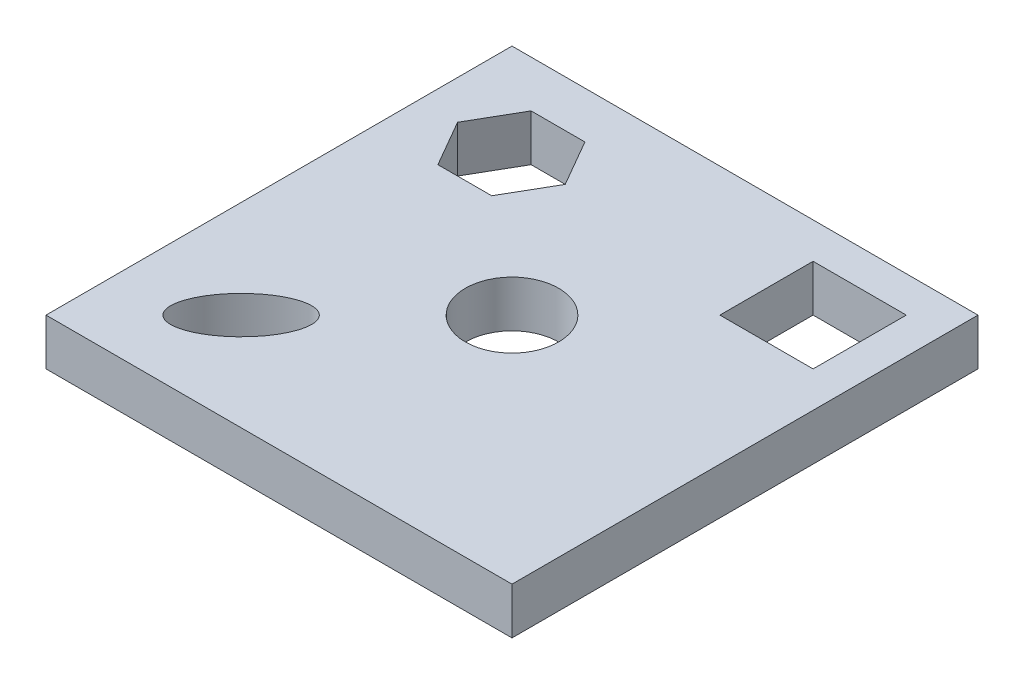
from build123d import *

# Parameters (mm, degrees)
SKETCH1_W           = 100
SKETCH1_H           = 100
SKETCH1_R           = 10
SKETCH1_RX          = 11.867112324
SKETCH1_RY          = 5.7171528
SKETCH1_W_2         = 20
SKETCH1_H_2         = 20
BOSS_EXTRUDE1_DEPTH = 10


with BuildPart() as part:
    # Sketch1 → Boss-Extrude1 (new body)
    with BuildSketch(Plane(origin=(0, 0, 0), x_dir=(1, 0, 0), z_dir=(0, 1, 0))):
        Rectangle(SKETCH1_W, SKETCH1_H)
        Circle(SKETCH1_R, mode=Mode.SUBTRACT)
        with Locations(Location((-29.06507818, -29.06507818), (0, 0, 45))):
            Ellipse(SKETCH1_RX, SKETCH1_RY, mode=Mode.SUBTRACT)
        Polygon((-18.581564885, 30), (-24.355067577, 40), (-35.902072961, 40), (-41.675575653, 30), (-35.902072961, 20), (-24.355067577, 20), align=None, mode=Mode.SUBTRACT)
        with Locations((32.305830442, 32.305830442)):
            Rectangle(SKETCH1_W_2, SKETCH1_H_2, mode=Mode.SUBTRACT)
    extrude(amount=BOSS_EXTRUDE1_DEPTH)


solid = part.part
